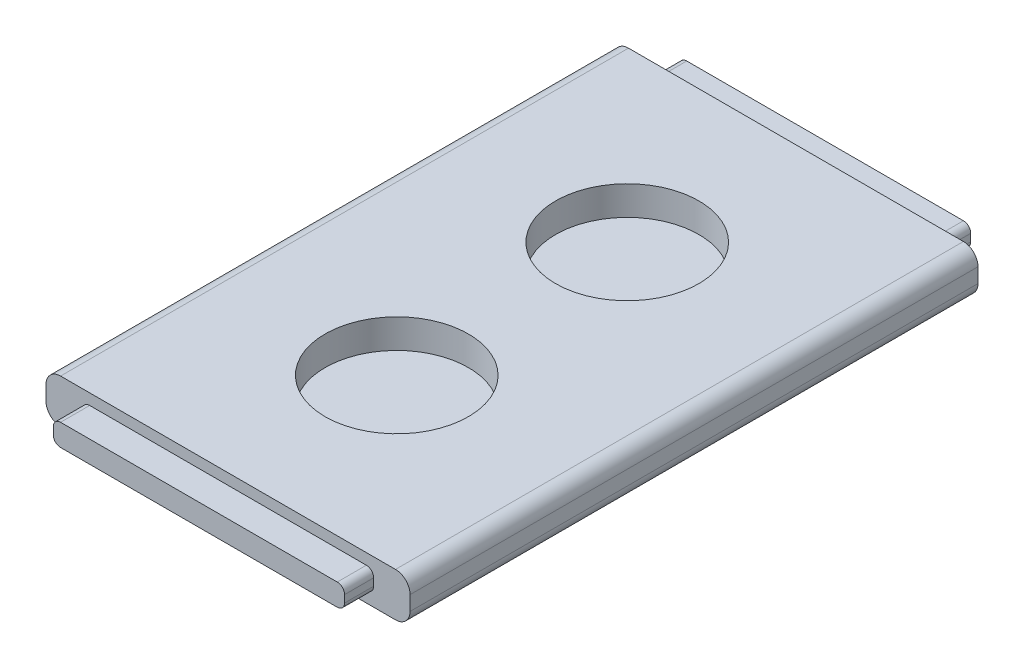
from build123d import *

# Parameters (mm, degrees)
SKETCH1_W           = 63.5
SKETCH1_H           = 99.06
BOSS_EXTRUDE1_DEPTH = 7.62
SKETCH2_R           = 12.5
CUT_EXTRUDE1_DEPTH  = 5.08
FILLET1_R           = 2.54
SKETCH3_W           = 50.8
SKETCH3_H           = 3.81
BOSS_EXTRUDE2_DEPTH = 5.08
FILLET2_R           = 1.27
SKETCH4_W           = 50.8
SKETCH4_H           = 3.81
BOSS_EXTRUDE3_DEPTH = 5.08
FILLET3_R           = 1.27


with BuildPart() as part:
    # Sketch1 → Boss-Extrude1 (new body)
    with BuildSketch(Plane(origin=(0, 0, 0), x_dir=(1, 0, 0), z_dir=(0, 1, 0))):
        Rectangle(SKETCH1_W, SKETCH1_H)
    extrude(amount=BOSS_EXTRUDE1_DEPTH)

    # Sketch2 → Cut-Extrude1 (cut)
    with BuildSketch(Plane(origin=(0, 7.62, 0), x_dir=(1, 0, 0), z_dir=(0, 1, 0))):
        with Locations((0, -20.1)):
            Circle(SKETCH2_R)
        with Locations((0, 20.1)):
            Circle(SKETCH2_R)
    extrude(amount=-CUT_EXTRUDE1_DEPTH, mode=Mode.SUBTRACT)

    # Fillet1
    fillet1_edges = [part.edges().sort_by_distance(p)[0] for p in [
        (-31.75, 7.62, 0),
        (31.75, 7.62, 0),
        (-31.75, 0, 0),
        (31.75, 0, 0),
    ]]
    fillet(fillet1_edges, radius=FILLET1_R)

    # Sketch3 → Boss-Extrude2 (add)
    with BuildSketch(Plane.XY.offset(49.53)):
        with Locations((0, 3.81)):
            Rectangle(SKETCH3_W, SKETCH3_H)
    extrude(amount=BOSS_EXTRUDE2_DEPTH)

    # Fillet2
    fillet2_edges = [part.edges().sort_by_distance(p)[0] for p in [
        (-25.4, 5.715, 52.07),
        (-25.4, 1.905, 52.07),
        (25.4, 1.905, 52.07),
        (25.4, 5.715, 52.07),
    ]]
    fillet(fillet2_edges, radius=FILLET2_R)

    # Sketch4 → Boss-Extrude3 (add)
    with BuildSketch(Plane(origin=(0, 0, -49.53), x_dir=(-1, 0, 0), z_dir=(0, 0, -1))):
        with Locations((0, 3.772103496)):
            Rectangle(SKETCH4_W, SKETCH4_H)
    extrude(amount=BOSS_EXTRUDE3_DEPTH)

    # Fillet3
    fillet3_edges = [part.edges().sort_by_distance(p)[0] for p in [
        (-25.4, 1.867103496, -52.07),
        (-25.4, 5.677103496, -52.07),
        (25.4, 5.677103496, -52.07),
        (25.4, 1.867103496, -52.07),
    ]]
    fillet(fillet3_edges, radius=FILLET3_R)


solid = part.part
